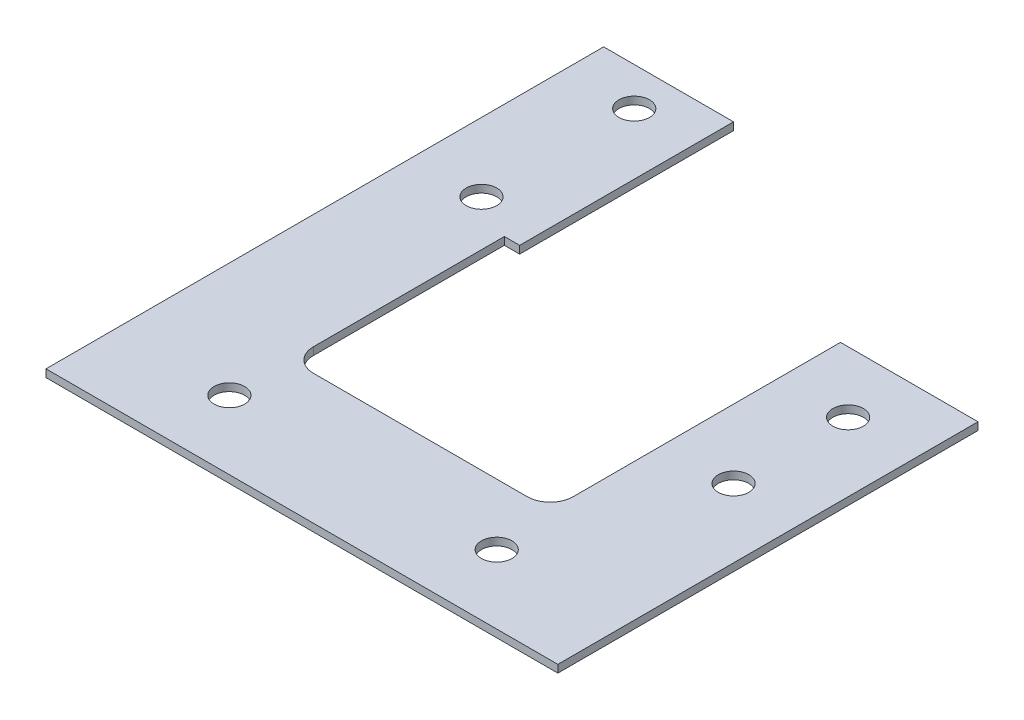
from build123d import *

# Parameters (mm, degrees)
SKETCH1_R           = 2
BOSS_EXTRUDE2_DEPTH = 1


with BuildPart() as part:
    # Sketch1 → Boss-Extrude2 (new body)
    with BuildSketch(Plane(origin=(0, 0, 0), x_dir=(1, 0, 0), z_dir=(0, 1, 0))):
        with BuildLine():
            Line((0, 40), (15, 40))
            Line((15, 40), (15, 0))
            Line((15, 0), (15, -15))
            Line((15, -15), (-52, -15))
            Line((-52, -15), (-52, 58))
            Line((-52, 58), (-37, 58))
            Line((-37, 58), (-35, 58))
            Line((-35, 58), (-35, 30))
            Line((-35, 30), (-37, 30))
            Line((-37, 30), (-37, 5))
            ThreePointArc((-37, 5), (-36.121320344, 2.878679656), (-34, 2))
            Line((-34, 2), (-6, 2))
            ThreePointArc((-6, 2), (-3.878679656, 2.878679656), (-3, 5))
            Line((-3, 5), (-3, 40))
            Line((-3, 40), (0, 40))
        make_face()
        with Locations((6, 32)):
            Circle(SKETCH1_R, mode=Mode.SUBTRACT)
        with Locations((6, 17)):
            Circle(SKETCH1_R, mode=Mode.SUBTRACT)
        with Locations((-43, 53)):
            Circle(SKETCH1_R, mode=Mode.SUBTRACT)
        with Locations((-43, 33)):
            Circle(SKETCH1_R, mode=Mode.SUBTRACT)
        with Locations((-37, -6)):
            Circle(SKETCH1_R, mode=Mode.SUBTRACT)
        with Locations((-2, -6)):
            Circle(SKETCH1_R, mode=Mode.SUBTRACT)
    extrude(amount=BOSS_EXTRUDE2_DEPTH)


solid = part.part
